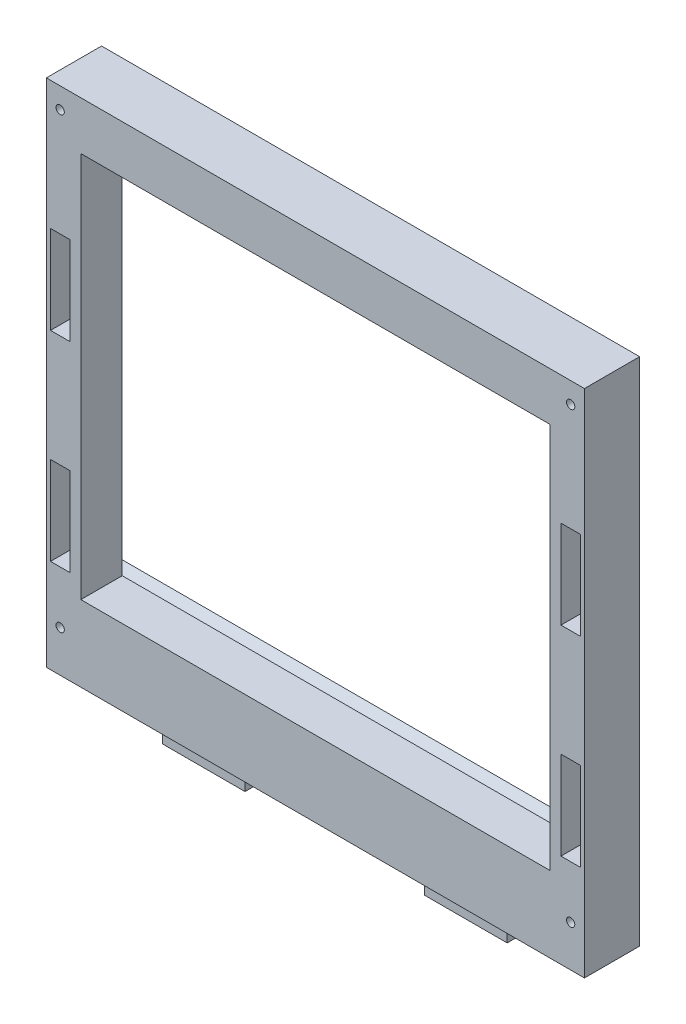
from build123d import *

# Parameters (mm, degrees)
ESBO_O1_W                = 195
ESBO_O1_H                = 185
RESSALTO_EXTRUS_O1_DEPTH = 20
ESBO_O2_W                = 30
ESBO_O2_H                = 6
RESSALTO_EXTRUS_O2_DEPTH = 10
ESBO_O3_W                = 7
ESBO_O3_H                = 32
CORTE_EXTRUS_O1_DEPTH    = 10
ESBO_O5_R                = 1.5
CORTE_EXTRUS_O3_DEPTH    = 8
ESBO_O6_R                = 1.5
CORTE_EXTRUS_O4_DEPTH    = 21
ESBO_O8_W                = 170
ESBO_O8_H                = 140
CORTE_EXTRUS_O6_DEPTH    = 21
CORTE_EXTRUS_O7_DEPTH    = 190


with BuildPart() as part:
    # Esboço1 → Ressalto-extrusão1 (new body)
    with BuildSketch(Plane.XY):
        Rectangle(ESBO_O1_W, ESBO_O1_H)
    extrude(amount=RESSALTO_EXTRUS_O1_DEPTH)

    # Esboço2 → Ressalto-extrusão2 (add)
    with BuildSketch(Plane.XZ.offset(92.5)):
        with Locations((-47.5, 10)):
            Rectangle(ESBO_O2_W, ESBO_O2_H)
        with Locations((47.5, 10)):
            Rectangle(ESBO_O2_W, ESBO_O2_H)
    extrude(amount=RESSALTO_EXTRUS_O2_DEPTH)

    # Esboço3 → Corte-extrusão1 (cut)
    with BuildSketch(Plane.XY.offset(20)):
        with Locations((-92.5, 30)):
            Rectangle(ESBO_O3_W, ESBO_O3_H)
        with Locations((-92.5, -42.5)):
            Rectangle(ESBO_O3_W, ESBO_O3_H)
        with Locations((92.5, -42.5)):
            Rectangle(ESBO_O3_W, ESBO_O3_H)
        with Locations((92.5, 30)):
            Rectangle(ESBO_O3_W, ESBO_O3_H)
    extrude(amount=-CORTE_EXTRUS_O1_DEPTH, mode=Mode.SUBTRACT)

    # Esboço5 → Corte-extrusão3 (cut)
    with BuildSketch(Plane.XZ.offset(92.5)):
        with Locations((-92.5, 10)):
            Circle(ESBO_O5_R)
        with Locations((92.5, 10)):
            Circle(ESBO_O5_R)
    extrude(amount=-CORTE_EXTRUS_O3_DEPTH, mode=Mode.SUBTRACT)

    # Esboço6 → Corte-extrusão4 (cut, through all)
    with BuildSketch(Plane(origin=(0, 0, 0), x_dir=(-1, 0, 0), z_dir=(0, 0, -1))):
        with Locations((-92.5, 85)):
            Circle(ESBO_O6_R)
        with Locations((92.5, 85)):
            Circle(ESBO_O6_R)
        with Locations((-92.5, -77.5)):
            Circle(ESBO_O6_R)
        with Locations((92.5, -77.5)):
            Circle(ESBO_O6_R)
    extrude(amount=-CORTE_EXTRUS_O4_DEPTH, mode=Mode.SUBTRACT)

    # Esboço8 → Corte-extrusão6 (cut, through all)
    with BuildSketch(Plane(origin=(0, 0, 0), x_dir=(-1, 0, 0), z_dir=(0, 0, -1))):
        with Locations((0, 5)):
            Rectangle(ESBO_O8_W, ESBO_O8_H)
    extrude(amount=-CORTE_EXTRUS_O6_DEPTH, mode=Mode.SUBTRACT)

    # Esboço9 → Corte-extrusão7 (cut)
    with BuildSketch(Plane.ZY.offset(97.5)):
        Polygon((0, -65), (0, 75), (5, 78.501037691), (5, -68.501037691), align=None)
    extrude(amount=-CORTE_EXTRUS_O7_DEPTH, mode=Mode.SUBTRACT)


solid = part.part
